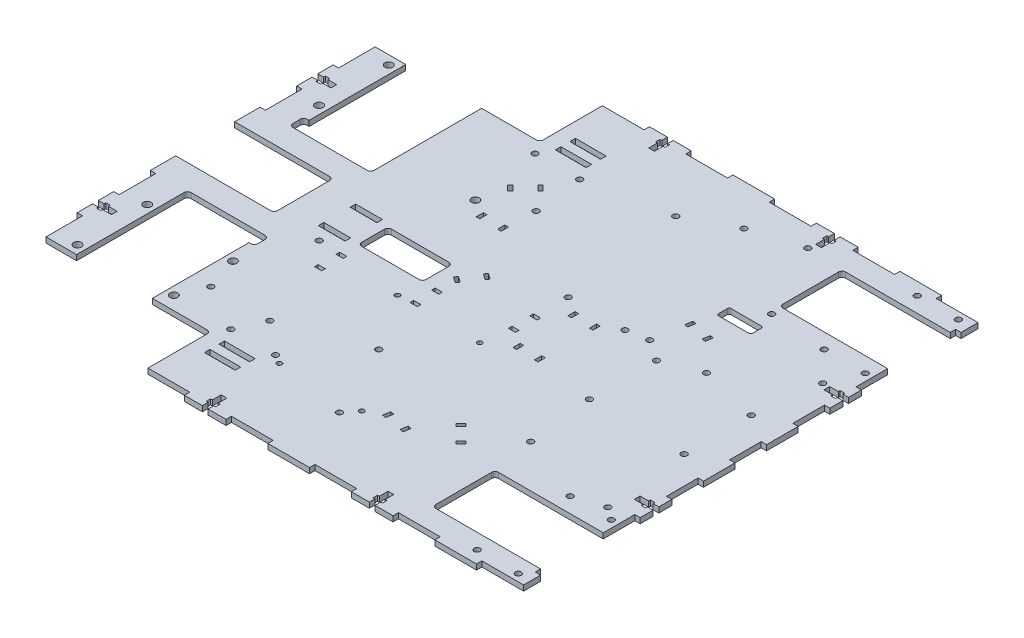
from build123d import *

# Parameters (mm, degrees)
SKETCH1_R                        = 1.65
BASE_DEPTH                       = 3
SKETCH10_R                       = 2.175
MOTORMOUNTS_DEPTH                = 1
MOTORMOUNTS_DEPTH_BACK           = 4
SKETCH2_R                        = 1.65
LINEFOLLOW_DEPTH                 = 1
LINEFOLLOW_DEPTH_BACK            = 4
SKETCH3_R                        = 1.65
MOBO_DEPTH                       = 1
MOBO_DEPTH_BACK                  = 4
SKETCH4_R                        = 1.65
HBRIDGE_DEPTH                    = 1
HBRIDGE_DEPTH_BACK               = 4
SKETCH6_W                        = 36
SKETCH6_H                        = 16.7
GEARCLEARENCE_DEPTH              = 1
GEARCLEARENCE_DEPTH_BACK         = 4
SKETCH7_R                        = 1.65
SKETCH7_W                        = 15
SKETCH7_H                        = 3.1
SKETCH7_W_2                      = 17.1577
GEARMOUNTING_DEPTH               = 1
GEARMOUNTING_DEPTH_BACK          = 4
SKETCH5_W                        = 3
SKETCH5_H                        = 20.444444444
SKETCH5_H_2                      = 17.666666667
SKETCH5_H_3                      = 17.666666666
SKETCH5_W_2                      = 23.333333333
SKETCH5_H_4                      = 3
SKETCH5_W_3                      = 23.333333334
FINGERJOINTS_DEPTH               = 1
FINGERJOINTS_DEPTH_BACK          = 4
BOLTMOUNTING_DEPTH               = 1
BOLTMOUNTING_DEPTH_BACK          = 4
SKETCH9_W                        = 55
SKETCH9_H                        = 33
HOOKCLEARENCE_DEPTH              = 1
HOOKCLEARENCE_DEPTH_BACK         = 4
SKETCH11_R                       = 1.65
POTENTIOMETERMOUNTING_DEPTH      = 1
POTENTIOMETERMOUNTING_DEPTH_BACK = 4
SKETCH13_R                       = 1.35
POWERBOARDMOUNTING_DEPTH         = 1
POWERBOARDMOUNTING_DEPTH_BACK    = 4
SKETCH12_R                       = 1.65
SERVOMOUNTING_DEPTH              = 1
SERVOMOUNTING_DEPTH_BACK         = 4
SKETCH14_R                       = 1.65
BATTERYMOUNTING_DEPTH            = 1
BATTERYMOUNTING_DEPTH_BACK       = 4
SKETCH15_W                       = 4
SKETCH15_H                       = 2
SKETCH15_W_2                     = 2
SKETCH15_H_2                     = 4
WIREROUTING_DEPTH                = 1
WIREROUTING_DEPTH_BACK           = 4
FILLET2_R                        = 2


with BuildPart() as part:
    # Sketch1 → Base (new body)
    with BuildSketch(Plane(origin=(0, 0, 0), x_dir=(1, 0, 0), z_dir=(0, 1, 0))):
        Polygon((-132.3981, 92), (-152.5, 92), (-152.5, -92), (-132.3981, -92), (-132.3981, -30), (-90.0019, -30), (-87.0019, -30), (-87.0019, -38), (-90.0019, -38), (-90.0019, -92), (-57.5, -92), (-57.5, -130), (152.5, -130), (152.5, -114.5), (89, -114.5), (89, -79.5), (152.5, -79.5), (152.5, 79.5), (89, 79.5), (89, 114.5), (152.5, 114.5), (152.5, 130), (-57.5, 130), (-57.5, 92), (-90.0019, 92), (-90.0019, 30), (-132.3981, 30), (-135.3981, 30), (-135.3981, 38), (-132.3981, 38), align=None)
        with Locations((122.5, -123)):
            Circle(SKETCH1_R, mode=Mode.SUBTRACT)
        with Locations((145.5, -123)):
            Circle(SKETCH1_R, mode=Mode.SUBTRACT)
        with Locations((122.5, -71)):
            Circle(SKETCH1_R, mode=Mode.SUBTRACT)
        with Locations((145.5, -71)):
            Circle(SKETCH1_R, mode=Mode.SUBTRACT)
        with Locations((122.5, 71)):
            Circle(SKETCH1_R, mode=Mode.SUBTRACT)
        with Locations((145.5, 71)):
            Circle(SKETCH1_R, mode=Mode.SUBTRACT)
        with Locations((122.5, 123)):
            Circle(SKETCH1_R, mode=Mode.SUBTRACT)
        with Locations((145.5, 123)):
            Circle(SKETCH1_R, mode=Mode.SUBTRACT)
    extrude(amount=BASE_DEPTH)

    # Sketch10 → MotorMounts (cut, two sides)
    with BuildSketch(Plane(origin=(0, 3, 0), x_dir=(1, 0, 0), z_dir=(0, 1, 0))) as motormounts_sk:
        with Locations((-136.8906, 87)):
            Circle(SKETCH10_R)
        with Locations((-136.8906, 48)):
            Circle(SKETCH10_R)
        with Locations((-47.3096, 45.8)):
            Circle(SKETCH10_R)
        with Locations((-136.8906, -48)):
            Circle(SKETCH10_R)
        with Locations((-136.8906, -87)):
            Circle(SKETCH10_R)
        with Locations((-85.5093, -84.5)):
            Circle(SKETCH10_R)
        with Locations((-85.5093, -51.5)):
            Circle(SKETCH10_R)
    extrude(amount=MOTORMOUNTS_DEPTH, mode=Mode.SUBTRACT)
    extrude(motormounts_sk.sketch, amount=-MOTORMOUNTS_DEPTH_BACK, mode=Mode.SUBTRACT)

    # Sketch2 → LineFollow (cut, two sides)
    with BuildSketch(Plane(origin=(0, 3, 0), x_dir=(1, 0, 0), z_dir=(0, 1, 0))) as linefollow_sk:
        with Locations((81, 18.75)):
            Circle(SKETCH2_R)
        with Locations((134, 18.75)):
            Circle(SKETCH2_R)
        with Locations((134, -18.75)):
            Circle(SKETCH2_R)
        with Locations((81, -18.75)):
            Circle(SKETCH2_R)
    extrude(amount=LINEFOLLOW_DEPTH, mode=Mode.SUBTRACT)
    extrude(linefollow_sk.sketch, amount=-LINEFOLLOW_DEPTH_BACK, mode=Mode.SUBTRACT)

    # Sketch3 → Mobo (cut, two sides)
    with BuildSketch(Plane(origin=(0, 3, 0), x_dir=(1, 0, 0), z_dir=(0, 1, 0))) as mobo_sk:
        with Locations((69.205, 26.774)):
            Circle(SKETCH3_R)
        with Locations((100.955, 26.774)):
            Circle(SKETCH3_R)
        with Locations((85.08, -55.649)):
            Circle(SKETCH3_R)
        with Locations((138.42, 54.206)):
            Circle(SKETCH3_R)
        with Locations((138.42, -65.809)):
            Circle(SKETCH3_R)
        with BuildLine():
            Line((76.64, 57.786), (93.64, 57.786))
            ThreePointArc((93.64, 57.786), (94.347106781, 58.078893219), (94.64, 58.786))
            Line((94.64, 58.786), (94.64, 63.786))
            ThreePointArc((94.64, 63.786), (94.347106781, 64.493106781), (93.64, 64.786))
            Line((93.64, 64.786), (76.64, 64.786))
            ThreePointArc((76.64, 64.786), (75.932893219, 64.493106781), (75.64, 63.786))
            Line((75.64, 63.786), (75.64, 58.786))
            ThreePointArc((75.64, 58.786), (75.932893219, 58.078893219), (76.64, 57.786))
        make_face()
    extrude(amount=MOBO_DEPTH, mode=Mode.SUBTRACT)
    extrude(mobo_sk.sketch, amount=-MOBO_DEPTH_BACK, mode=Mode.SUBTRACT)

    # Sketch4 → HBridge (cut, two sides)
    with BuildSketch(Plane(origin=(0, 3, 0), x_dir=(1, 0, 0), z_dir=(0, 1, 0))) as hbridge_sk:
        with Locations((25.678, 24.699)):
            Circle(SKETCH4_R)
        with Locations((57.428, 24.699)):
            Circle(SKETCH4_R)
        with Locations((41.553, 107.122)):
            Circle(SKETCH4_R)
    extrude(amount=HBRIDGE_DEPTH, mode=Mode.SUBTRACT)
    extrude(hbridge_sk.sketch, amount=-HBRIDGE_DEPTH_BACK, mode=Mode.SUBTRACT)

    # Sketch6 → GearClearence (cut, two sides)
    with BuildSketch(Plane(origin=(0, 3, 0), x_dir=(1, 0, 0), z_dir=(0, 1, 0))) as gearclearence_sk:
        with Locations((-40.6638, 0)):
            Rectangle(SKETCH6_W, SKETCH6_H)
    extrude(amount=GEARCLEARENCE_DEPTH, mode=Mode.SUBTRACT)
    extrude(gearclearence_sk.sketch, amount=-GEARCLEARENCE_DEPTH_BACK, mode=Mode.SUBTRACT)

    # Sketch7 → GearMounting (cut, two sides)
    with BuildSketch(Plane(origin=(0, 3, 0), x_dir=(1, 0, 0), z_dir=(0, 1, 0))) as gearmounting_sk:
        with Locations((-53.1638, 85)):
            Circle(SKETCH7_R)
        with Locations((-28.1638, 85)):
            Circle(SKETCH7_R)
        with Locations((-28.1638, -85)):
            Circle(SKETCH7_R)
        with Locations((-53.1638, -85)):
            Circle(SKETCH7_R)
        with Locations((-71.3576, -17.45025)):
            Circle(SKETCH7_R)
        with Locations((-71.3576, 8.90025)):
            Rectangle(SKETCH7_W, SKETCH7_H)
        with Locations((-71.3576, -8.90025)):
            Rectangle(SKETCH7_W, SKETCH7_H)
        with Locations((-40.6638, 102.15)):
            Rectangle(SKETCH7_W_2, SKETCH7_H)
        with Locations((-40.6638, 94.05)):
            Rectangle(SKETCH7_W_2, SKETCH7_H)
        with Locations((-40.6638, -94.05)):
            Rectangle(SKETCH7_W_2, SKETCH7_H)
        with Locations((-40.6638, -102.15)):
            Rectangle(SKETCH7_W_2, SKETCH7_H)
    extrude(amount=GEARMOUNTING_DEPTH, mode=Mode.SUBTRACT)
    extrude(gearmounting_sk.sketch, amount=-GEARMOUNTING_DEPTH_BACK, mode=Mode.SUBTRACT)

    # Sketch5 → FingerJoints (cut, two sides)
    with BuildSketch(Plane(origin=(0, 3, 0), x_dir=(1, 0, 0), z_dir=(0, 1, 0))) as fingerjoints_sk:
        with Locations((-151, 81.777777778)):
            Rectangle(SKETCH5_W, SKETCH5_H)
        with Locations((-151, 40.888888889)):
            Rectangle(SKETCH5_W, SKETCH5_H)
        with Locations((-151, 0)):
            Rectangle(SKETCH5_W, SKETCH5_H)
        with Locations((-151, -40.888888889)):
            Rectangle(SKETCH5_W, SKETCH5_H)
        with Locations((-151, -81.777777778)):
            Rectangle(SKETCH5_W, SKETCH5_H)
        with Locations((151, 70.666666667)):
            Rectangle(SKETCH5_W, SKETCH5_H_2)
        with Locations((151, 35.333333334)):
            Rectangle(SKETCH5_W, SKETCH5_H_2)
        with Locations((151, 0)):
            Rectangle(SKETCH5_W, SKETCH5_H_3)
        with Locations((151, -35.333333334)):
            Rectangle(SKETCH5_W, SKETCH5_H_2)
        with Locations((151, -70.666666667)):
            Rectangle(SKETCH5_W, SKETCH5_H_2)
        with Locations((-45.833333334, 128.5)):
            Rectangle(SKETCH5_W_2, SKETCH5_H_4)
        with Locations((0.833333333, 128.5)):
            Rectangle(SKETCH5_W_2, SKETCH5_H_4)
        with Locations((47.5, 128.5)):
            Rectangle(SKETCH5_W_3, SKETCH5_H_4)
        with Locations((94.166666667, 128.5)):
            Rectangle(SKETCH5_W_2, SKETCH5_H_4)
        with Locations((140.833333334, 128.5)):
            Rectangle(SKETCH5_W_2, SKETCH5_H_4)
        with Locations((151, 116)):
            Rectangle(SKETCH5_W, SKETCH5_H_4)
        with Locations((151, -116)):
            Rectangle(SKETCH5_W, SKETCH5_H_4)
        with Locations((140.833333334, -128.5)):
            Rectangle(SKETCH5_W_2, SKETCH5_H_4)
        with Locations((94.166666667, -128.5)):
            Rectangle(SKETCH5_W_2, SKETCH5_H_4)
        with Locations((47.5, -128.5)):
            Rectangle(SKETCH5_W_3, SKETCH5_H_4)
        with Locations((0.833333333, -128.5)):
            Rectangle(SKETCH5_W_2, SKETCH5_H_4)
        with Locations((-45.833333334, -128.5)):
            Rectangle(SKETCH5_W_2, SKETCH5_H_4)
    extrude(amount=FINGERJOINTS_DEPTH, mode=Mode.SUBTRACT)
    extrude(fingerjoints_sk.sketch, amount=-FINGERJOINTS_DEPTH_BACK, mode=Mode.SUBTRACT)

    # Sketch8 → BoltMounting (cut, two sides)
    with BuildSketch(Plane(origin=(0, 3, 0), x_dir=(1, 0, 0), z_dir=(0, 1, 0))) as boltmounting_sk:
        Polygon((-24.1, 124.325), (-24.1, 119.5), (-20.9, 119.5), (-20.9, 124.325), (-19.9, 124.325), (-19.9, 126.825), (-20.9, 126.825), (-20.9, 130), (-24.1, 130), (-24.1, 126.825), (-25.1, 126.825), (-25.1, 124.325), align=None)
        Polygon((69.233333333, 124.325), (69.233333333, 119.5), (72.433333333, 119.5), (72.433333333, 124.325), (73.433333333, 124.325), (73.433333333, 126.825), (72.433333333, 126.825), (72.433333333, 130), (69.233333333, 130), (69.233333333, 126.825), (68.233333333, 126.825), (68.233333333, 124.325), align=None)
        Polygon((72.433333333, -124.325), (72.433333333, -119.5), (69.233333333, -119.5), (69.233333333, -124.325), (68.233333333, -124.325), (68.233333333, -126.825), (69.233333333, -126.825), (69.233333333, -130), (72.433333333, -130), (72.433333333, -126.825), (73.433333333, -126.825), (73.433333333, -124.325), align=None)
        Polygon((-20.9, -119.5), (-24.1, -119.5), (-24.1, -124.325), (-25.1, -124.325), (-25.1, -126.825), (-24.1, -126.825), (-24.1, -130), (-20.9, -130), (-20.9, -126.825), (-19.9, -126.825), (-19.9, -124.325), (-20.9, -124.325), align=None)
        Polygon((146.825, 54.6), (142, 54.6), (142, 51.4), (146.825, 51.4), (146.825, 50.4), (149.325, 50.4), (149.325, 51.4), (152.5, 51.4), (152.5, 54.6), (149.325, 54.6), (149.325, 55.6), (146.825, 55.6), align=None)
        Polygon((146.825, -51.4), (142, -51.4), (142, -54.6), (146.825, -54.6), (146.825, -55.6), (149.325, -55.6), (149.325, -54.6), (152.5, -54.6), (152.5, -51.4), (149.325, -51.4), (149.325, -50.4), (146.825, -50.4), align=None)
        Polygon((-146.825, 59.733333333), (-142, 59.733333333), (-142, 62.933333333), (-146.825, 62.933333333), (-146.825, 63.933333333), (-149.325, 63.933333333), (-149.325, 62.933333333), (-152.5, 62.933333333), (-152.5, 59.733333333), (-149.325, 59.733333333), (-149.325, 58.733333333), (-146.825, 58.733333333), align=None)
        Polygon((-146.825, -62.933333333), (-142, -62.933333333), (-142, -59.733333333), (-146.825, -59.733333333), (-146.825, -58.733333333), (-149.325, -58.733333333), (-149.325, -59.733333333), (-152.5, -59.733333333), (-152.5, -62.933333333), (-149.325, -62.933333333), (-149.325, -63.933333333), (-146.825, -63.933333333), align=None)
    extrude(amount=BOLTMOUNTING_DEPTH, mode=Mode.SUBTRACT)
    extrude(boltmounting_sk.sketch, amount=-BOLTMOUNTING_DEPTH_BACK, mode=Mode.SUBTRACT)

    # Sketch9 → HookClearence (cut, two sides)
    with BuildSketch(Plane(origin=(0, 3, 0), x_dir=(1, 0, 0), z_dir=(0, 1, 0))) as hookclearence_sk:
        with Locations((-125, 0)):
            Rectangle(SKETCH9_W, SKETCH9_H)
    extrude(amount=HOOKCLEARENCE_DEPTH, mode=Mode.SUBTRACT)
    extrude(hookclearence_sk.sketch, amount=-HOOKCLEARENCE_DEPTH_BACK, mode=Mode.SUBTRACT)

    # Sketch11 → PotentiometerMounting (cut, two sides)
    with BuildSketch(Plane(origin=(0, 3, 0), x_dir=(1, 0, 0), z_dir=(0, 1, 0))) as potentiometermounting_sk:
        with Locations((-79.3388, -70)):
            Circle(SKETCH11_R)
        with Locations((-46.3388, -70)):
            Circle(SKETCH11_R)
    extrude(amount=POTENTIOMETERMOUNTING_DEPTH, mode=Mode.SUBTRACT)
    extrude(potentiometermounting_sk.sketch, amount=-POTENTIOMETERMOUNTING_DEPTH_BACK, mode=Mode.SUBTRACT)

    # Sketch13 → PowerBoardMounting (cut, two sides)
    with BuildSketch(Plane(origin=(0, 3, 0), x_dir=(1, 0, 0), z_dir=(0, 1, 0))) as powerboardmounting_sk:
        with Locations((-23, -22)):
            Circle(SKETCH13_R)
        with Locations((23, -22)):
            Circle(SKETCH13_R)
        with Locations((-23, -88)):
            Circle(SKETCH13_R)
        with Locations((23, -88)):
            Circle(SKETCH13_R)
    extrude(amount=POWERBOARDMOUNTING_DEPTH, mode=Mode.SUBTRACT)
    extrude(powerboardmounting_sk.sketch, amount=-POWERBOARDMOUNTING_DEPTH_BACK, mode=Mode.SUBTRACT)

    # Sketch12 → ServoMounting (cut, two sides)
    with BuildSketch(Plane(origin=(0, 3, 0), x_dir=(1, 0, 0), z_dir=(0, 1, 0))) as servomounting_sk:
        with Locations((17.5, -95)):
            Circle(SKETCH12_R)
        with Locations((-2, -53.5)):
            Circle(SKETCH12_R)
    extrude(amount=SERVOMOUNTING_DEPTH, mode=Mode.SUBTRACT)
    extrude(servomounting_sk.sketch, amount=-SERVOMOUNTING_DEPTH_BACK, mode=Mode.SUBTRACT)

    # Sketch14 → BatteryMounting (cut, two sides)
    with BuildSketch(Plane(origin=(0, 3, 0), x_dir=(1, 0, 0), z_dir=(0, 1, 0))) as batterymounting_sk:
        with Locations((16.5, 94)):
            Circle(SKETCH14_R)
        with Locations((-25, 57.5)):
            Circle(SKETCH14_R)
        with Locations((90.65, 73.5)):
            Circle(SKETCH14_R)
        with Locations((68.85, 115.5)):
            Circle(SKETCH14_R)
    extrude(amount=BATTERYMOUNTING_DEPTH, mode=Mode.SUBTRACT)
    extrude(batterymounting_sk.sketch, amount=-BATTERYMOUNTING_DEPTH_BACK, mode=Mode.SUBTRACT)

    # Sketch15 → WireRouting (cut, two sides)
    with BuildSketch(Plane(origin=(0, 3, 0), x_dir=(1, 0, 0), z_dir=(0, 1, 0))) as wirerouting_sk:
        with Locations((-58, -18.35)):
            Rectangle(SKETCH15_W, SKETCH15_H)
        with Locations((-58, -30.35)):
            Rectangle(SKETCH15_W, SKETCH15_H)
        with Locations((-38, 40)):
            Rectangle(SKETCH15_W_2, SKETCH15_H_2)
        Polygon((73.459818362, 43.726514448), (74.154411072, 47.66574546), (72.184795566, 48.013041816), (71.490202856, 44.073810804), align=None)
        with Locations((35.553, 17.699)):
            Rectangle(SKETCH15_W_2, SKETCH15_H_2)
        with Locations((26, 6)):
            Rectangle(SKETCH15_W, SKETCH15_H)
        with Locations((26, -6)):
            Rectangle(SKETCH15_W, SKETCH15_H)
        with Locations((-14, -9)):
            Rectangle(SKETCH15_W, SKETCH15_H)
        with Locations((-26, 40)):
            Rectangle(SKETCH15_W_2, SKETCH15_H_2)
        Polygon((-37.121320344, 70.707106781), (-34.292893219, 67.878679656), (-32.878679656, 69.292893219), (-35.707106781, 72.121320344), align=None)
        Polygon((-45.606601718, 62.221825407), (-42.778174593, 59.393398282), (-41.363961031, 60.807611845), (-44.192388155, 63.636038969), align=None)
        Polygon((-9.328963289, 12.328000828), (-6.052355112, 10.033695083), (-4.905202239, 11.671999172), (-8.181810416, 13.966304917), align=None)
        Polygon((-16.211880525, 2.498176297), (-12.935272348, 0.203870552), (-11.788119475, 1.84217464), (-15.064727652, 4.136480386), align=None)
        with Locations((-14, -21)):
            Rectangle(SKETCH15_W, SKETCH15_H)
        with Locations((47.553, 17.699)):
            Rectangle(SKETCH15_W_2, SKETCH15_H_2)
        Polygon((85.277511398, 41.642736316), (85.972104108, 45.581967328), (84.002488602, 45.929263684), (83.307895892, 41.990032672), align=None)
        with Locations((35.553, -13)):
            Rectangle(SKETCH15_W_2, SKETCH15_H_2)
        with Locations((47.553, -13)):
            Rectangle(SKETCH15_W_2, SKETCH15_H_2)
        Polygon((56.807611845, -69.136038969), (59.636038969, -66.307611845), (58.221825407, -64.893398282), (55.393398282, -67.721825407), align=None)
        Polygon((65.292893219, -77.621320344), (68.121320344, -74.792893219), (66.707106781, -73.378679656), (63.878679656, -76.207106781), align=None)
        Polygon((32.819818362, -84.559485552), (33.514411072, -80.62025454), (31.544795566, -80.272958184), (30.850202856, -84.212189196), align=None)
        Polygon((44.637511398, -86.643263684), (45.332104108, -82.704032672), (43.362488602, -82.356736316), (42.667895892, -86.295967328), align=None)
    extrude(amount=WIREROUTING_DEPTH, mode=Mode.SUBTRACT)
    extrude(wirerouting_sk.sketch, amount=-WIREROUTING_DEPTH_BACK, mode=Mode.SUBTRACT)

    # Fillet2
    fillet2_edges = [part.edges().sort_by_distance(p)[0] for p in [
        (-97.5, 1.5, -16.5),
        (-97.5, 1.5, 16.5),
        (-22.6638, 1.5, 8.35),
        (-58.6638, 1.5, 8.35),
        (-58.6638, 1.5, -8.35),
        (-22.6638, 1.5, -8.35),
        (-132.3981, 1.5, 30),
        (-135.3981, 1.5, -38),
        (-135.3981, 1.5, -30),
        (-90.0019, 1.5, -30),
        (-57.5, 1.5, -92),
        (89, 1.5, -114.5),
        (89, 1.5, -79.5),
        (89, 1.5, 79.5),
        (89, 1.5, 114.5),
        (-57.5, 1.5, 92),
        (-87.0019, 1.5, 38),
        (-87.0019, 1.5, 30),
    ]]
    fillet(fillet2_edges, radius=FILLET2_R)


solid = part.part
